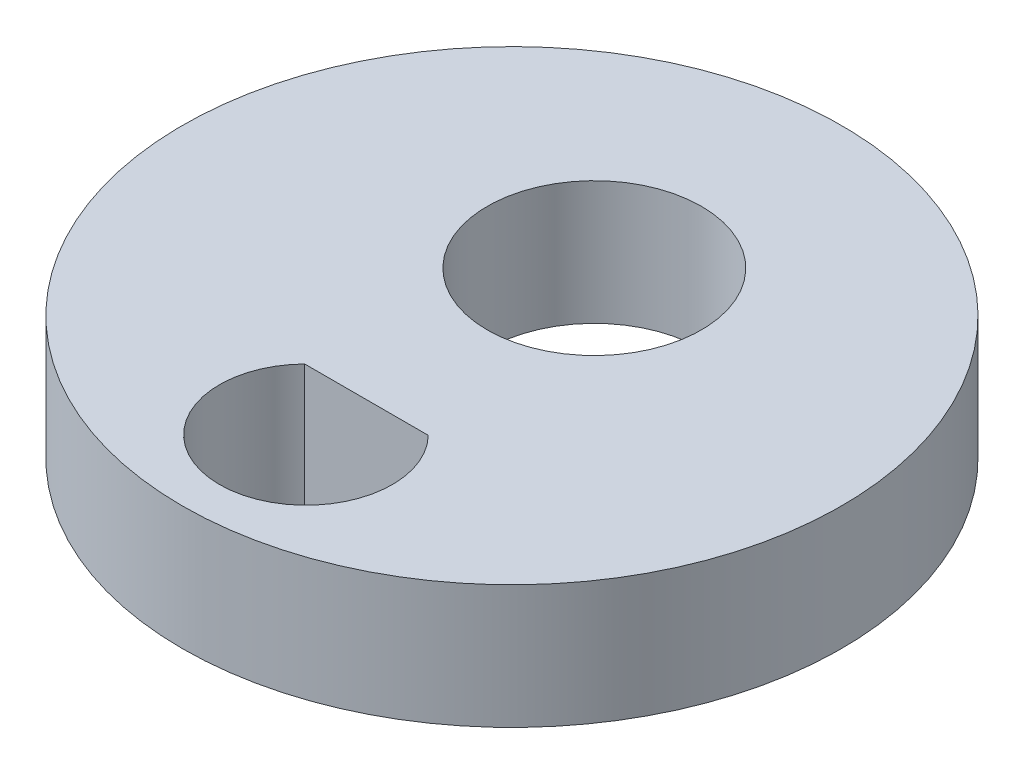
from build123d import *

# Parameters (mm, degrees)
SKETCH1_R           = 8
SKETCH1_R_2         = 2.6
BOSS_EXTRUDE1_DEPTH = 3


with BuildPart() as part:
    # Sketch1 → Boss-Extrude1 (new body)
    with BuildSketch(Plane(origin=(0, 0, 0), x_dir=(1, 0, 0), z_dir=(0, 1, 0))):
        Circle(SKETCH1_R)
        with Locations((0, 2)):
            Circle(SKETCH1_R_2, mode=Mode.SUBTRACT)
        with BuildLine():
            Line((1.5, -3.530306154), (-1.5, -3.530306154))
            ThreePointArc((-1.5, -3.530306154), (0, -7.1), (1.5, -3.530306154))
        make_face(mode=Mode.SUBTRACT)
    extrude(amount=BOSS_EXTRUDE1_DEPTH)


solid = part.part
